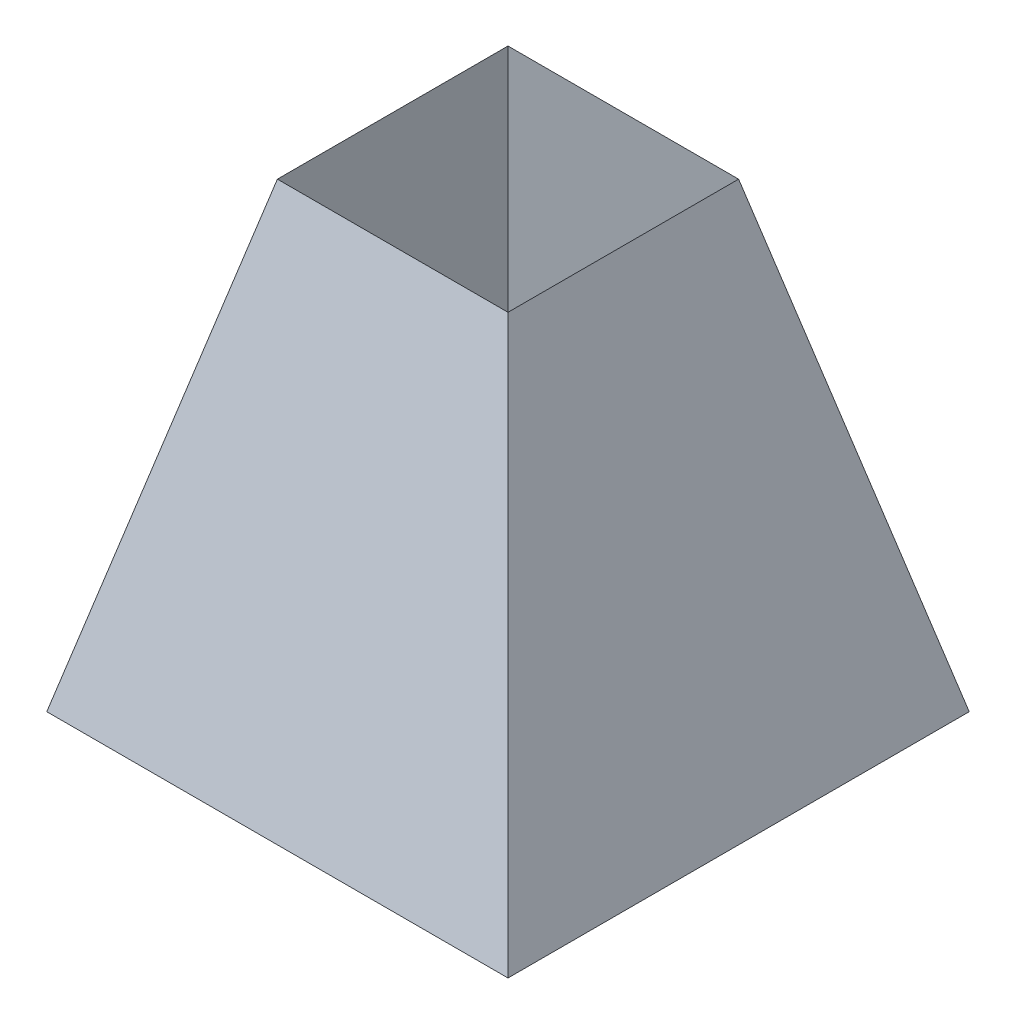
from build123d import *

# Parameters (mm, degrees)
SKETCH1_W          = 203.2
SKETCH1_H          = 203.2
SKETCH2_W          = 101.6
SKETCH2_H          = 101.6
SKETCH14_W         = 101.6
SKETCH14_H         = 101.6
CUT_EXTRUDE2_DEPTH = 203.2
CUT_EXTRUDE2_TAPER = -8


with BuildPart() as part:
    # Sketch1 → Loft1 section 0
    with BuildSketch(Plane(origin=(0, 0, 0), x_dir=(1, 0, 0), z_dir=(0, 1, 0))):
        Rectangle(SKETCH1_W, SKETCH1_H)
    # Sketch2 → Loft1 section 1
    with BuildSketch(Plane(origin=(0, 203.2, 0), x_dir=(1, 0, 0), z_dir=(0, 1, 0))):
        Rectangle(SKETCH2_W, SKETCH2_H)
    loft()

    # Sketch14 → Cut-Extrude2 (cut)
    with BuildSketch(Plane(origin=(0, 203.2, 0), x_dir=(1, 0, 0), z_dir=(0, 1, 0))):
        Rectangle(SKETCH14_W, SKETCH14_H)
    extrude(amount=-CUT_EXTRUDE2_DEPTH, taper=CUT_EXTRUDE2_TAPER, mode=Mode.SUBTRACT)


solid = part.part
